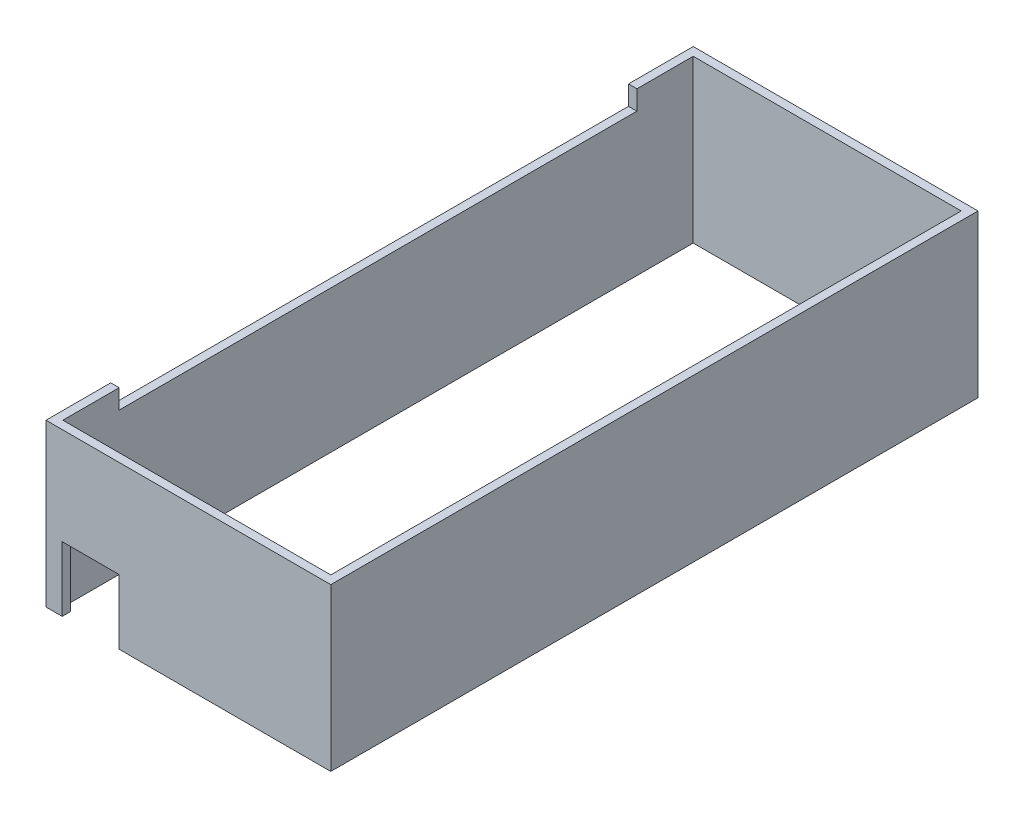
from build123d import *

# Parameters (mm, degrees)
SKETCH2_W           = 111.76
SKETCH2_H           = 254
SKETCH2_W_2         = 105.156
SKETCH2_H_2         = 247.396
BOSS_EXTRUDE2_DEPTH = 63.5
SKETCH3_W           = 203.2
SKETCH3_H           = 7.62
CUT_EXTRUDE1_DEPTH  = 63.5
CUT_EXTRUDE2_REACH  = 256
SKETCH4_W           = 22.352
SKETCH4_H           = 25.4


with BuildPart() as part:
    # Sketch2 → Boss-Extrude2 (new body)
    with BuildSketch(Plane(origin=(0, 0, 0), x_dir=(1, 0, 0), z_dir=(0, 1, 0))):
        with Locations((55.88, 127)):
            Rectangle(SKETCH2_W, SKETCH2_H)
        with Locations((55.88, 127)):
            Rectangle(SKETCH2_W_2, SKETCH2_H_2, mode=Mode.SUBTRACT)
    extrude(amount=BOSS_EXTRUDE2_DEPTH)

    # Sketch3 → Cut-Extrude1 (cut)
    with BuildSketch(Plane(origin=(3.302, 0, 0), x_dir=(0, 0, -1), z_dir=(1, 0, 0))):
        with Locations((127, 59.69)):
            Rectangle(SKETCH3_W, SKETCH3_H)
    extrude(amount=-CUT_EXTRUDE1_DEPTH, mode=Mode.SUBTRACT)

    # Sketch4 → Cut-Extrude2 (cut, up to next)
    with BuildSketch(Plane.XY, mode=Mode.PRIVATE) as cut_extrude2_sk1:
        with Locations((17.526, 12.7)):
            Rectangle(SKETCH4_W, SKETCH4_H)
    cut_extrude2_tool1 = extrude(cut_extrude2_sk1.sketch, amount=-CUT_EXTRUDE2_REACH, mode=Mode.PRIVATE) & part.part
    add(cut_extrude2_tool1.solids().sort_by_distance((17.526, 12.7, 0))[0], mode=Mode.SUBTRACT)


solid = part.part
